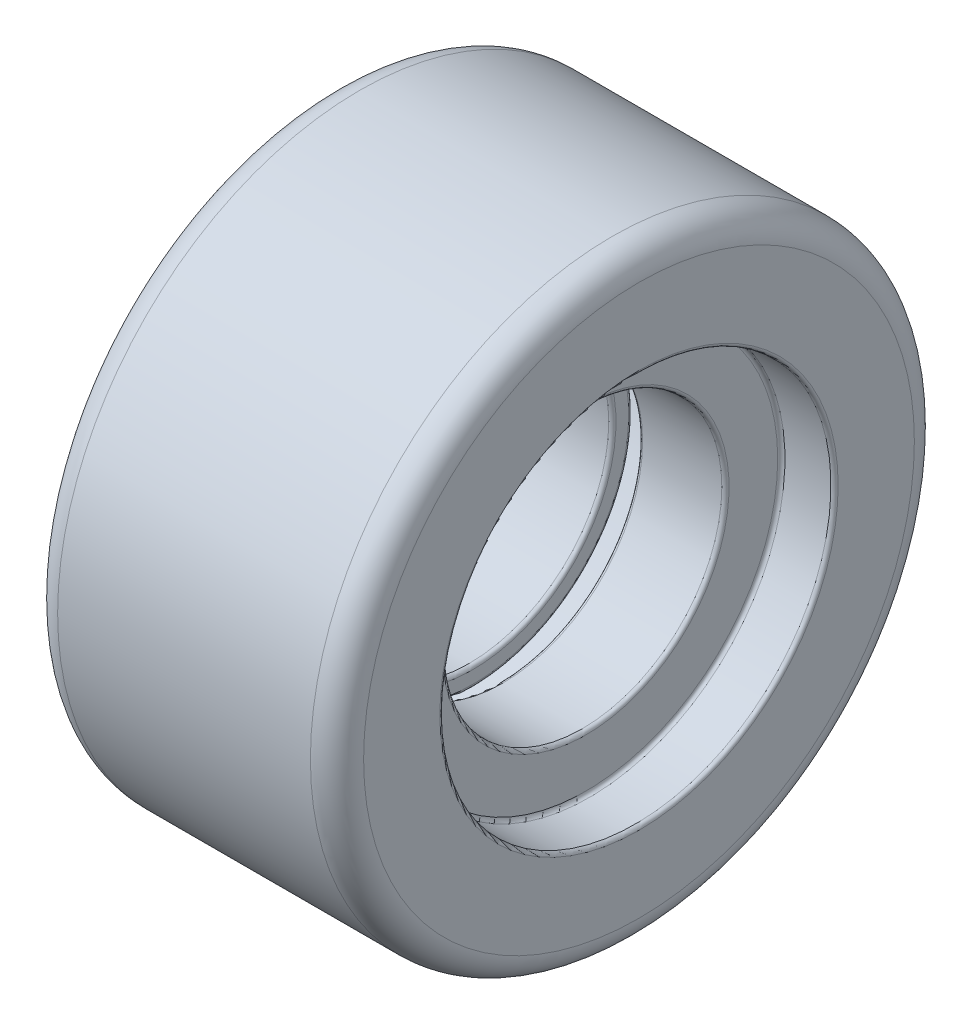
from build123d import *


with BuildPart() as part:
    # Sketch1 → Revolve1 (revolve)
    with BuildSketch(Plane.XY):
        with BuildLine():
            Line((57.285232446, 120), (12.714767554, 120))
            ThreePointArc((12.714767554, 120), (10.795137007, 119.204862993), (10, 117.285232446))
            Line((10, 117.285232446), (10, 107.714767554))
            ThreePointArc((10, 107.714767554), (10.795137007, 105.795137007), (12.714767554, 105))
            Line((12.714767554, 105), (72.285232446, 105))
            ThreePointArc((72.285232446, 105), (74.204862993, 105.795137007), (75, 107.714767554))
            Line((75, 107.714767554), (75, 144.285232446))
            ThreePointArc((75, 144.285232446), (75.795137007, 146.204862993), (77.714767554, 147))
            Line((77.714767554, 147), (112.285232446, 147))
            ThreePointArc((112.285232446, 147), (114.204862993, 147.795137007), (115, 149.714767554))
            Line((115, 149.714767554), (115, 207))
            ThreePointArc((115, 207), (109.142135624, 221.142135624), (95, 227))
            Line((95, 227), (-95, 227))
            ThreePointArc((-95, 227), (-109.142135624, 221.142135624), (-115, 207))
            Line((-115, 207), (-115, 149.714767554))
            ThreePointArc((-115, 149.714767554), (-114.204862993, 147.795137007), (-112.285232446, 147))
            Line((-112.285232446, 147), (-75, 147))
            Line((-75, 147), (-75, 107.714767554))
            ThreePointArc((-75, 107.714767554), (-74.204862993, 105.795137007), (-72.285232446, 105))
            Line((-72.285232446, 105), (-12.714767554, 105))
            ThreePointArc((-12.714767554, 105), (-10.795137007, 105.795137007), (-10, 107.714767554))
            Line((-10, 107.714767554), (-10, 117.285232446))
            ThreePointArc((-10, 117.285232446), (-10.795137007, 119.204862993), (-12.714767554, 120))
            Line((-12.714767554, 120), (-57.285232446, 120))
            ThreePointArc((-57.285232446, 120), (-59.204862993, 120.795137007), (-60, 122.714767554))
            Line((-60, 122.714767554), (-60, 159.285232446))
            ThreePointArc((-60, 159.285232446), (-60.795137007, 161.204862993), (-62.714767554, 162))
            Line((-62.714767554, 162), (-97.285232446, 162))
            ThreePointArc((-97.285232446, 162), (-99.204862993, 162.795137007), (-100, 164.714767554))
            Line((-100, 164.714767554), (-100, 209.285232446))
            ThreePointArc((-100, 209.285232446), (-99.204862993, 211.204862993), (-97.285232446, 212))
            Line((-97.285232446, 212), (97.285232446, 212))
            ThreePointArc((97.285232446, 212), (99.204862993, 211.204862993), (100, 209.285232446))
            Line((100, 209.285232446), (100, 164.714767554))
            ThreePointArc((100, 164.714767554), (99.204862993, 162.795137007), (97.285232446, 162))
            Line((97.285232446, 162), (62.714767554, 162))
            ThreePointArc((62.714767554, 162), (60.795137007, 161.204862993), (60, 159.285232446))
            Line((60, 159.285232446), (60, 122.714767554))
            ThreePointArc((60, 122.714767554), (59.204862993, 120.795137007), (57.285232446, 120))
        make_face()
    revolve(axis=Axis((-91.369863014, 0, 0), (1, 0, 0)))


solid = part.part
